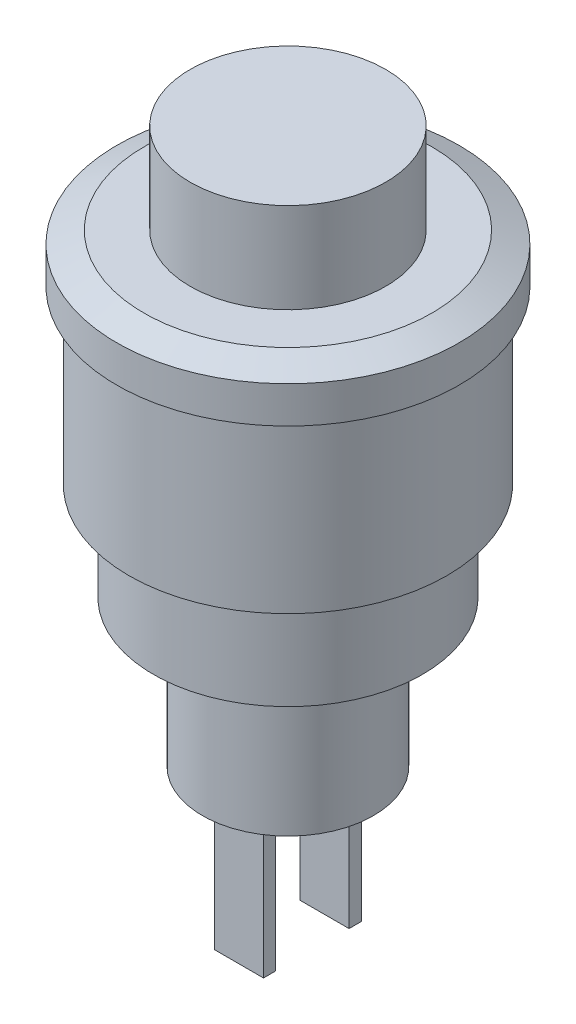
from build123d import *

# Parameters (mm, degrees)
ESBO_O2_W                = 2
ESBO_O2_H                = 0.5
RESSALTO_EXTRUS_O1_DEPTH = 6


with BuildPart() as part:
    # Esboço1 → Revolução1 (revolve)
    with BuildSketch(Plane.XY):
        Polygon((0, 22.689764513), (4, 22.689764513), (4, 19), (5.891304348, 19), (7, 18.5), (7, 17), (6.5, 17), (6.5, 10), (5.5, 10), (5.5, 6), (3.5, 6), (3.5, 0), (0, 0), align=None)
    revolve(axis=Axis((0, 0, 0), (0, 1, 0)))

    # Esboço2 → Ressalto-extrusão1 (add)
    with BuildSketch(Plane.XZ):
        with Locations((0, -1.75)):
            Rectangle(ESBO_O2_W, ESBO_O2_H)
        with Locations((0, 1.75)):
            Rectangle(ESBO_O2_W, ESBO_O2_H)
    extrude(amount=RESSALTO_EXTRUS_O1_DEPTH)


solid = part.part
